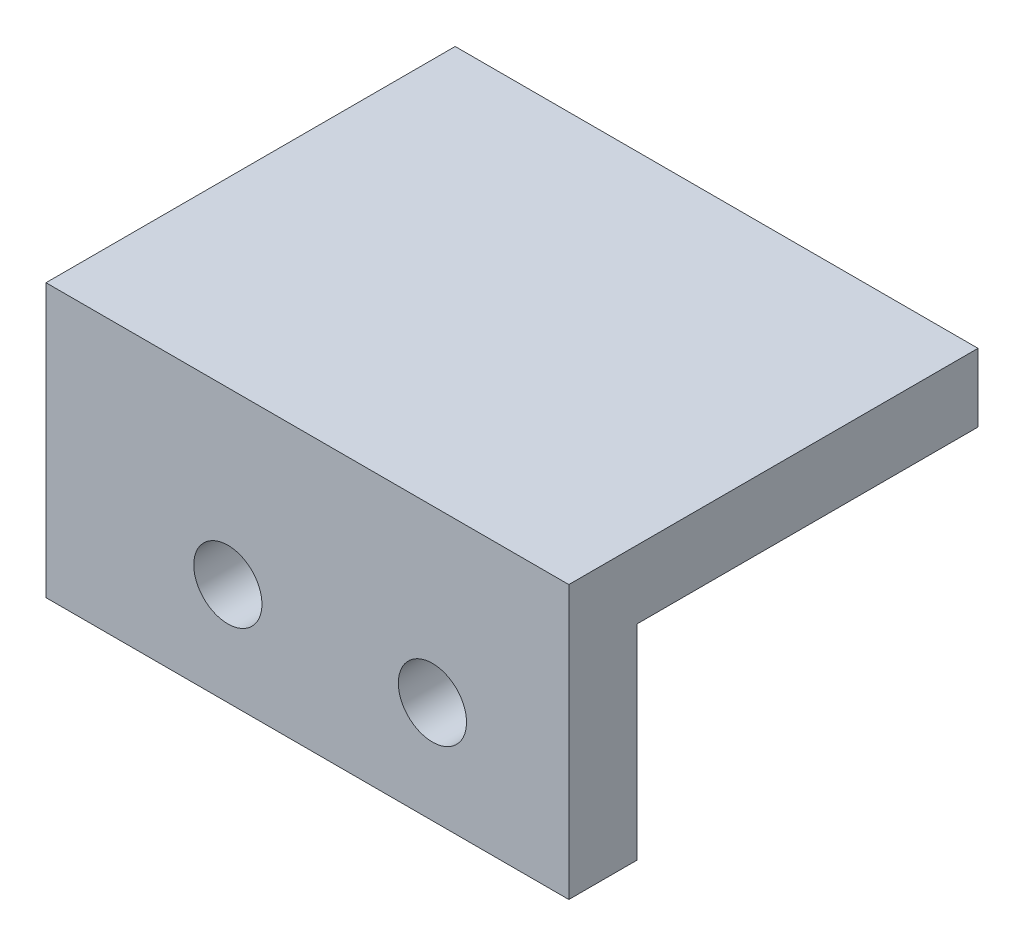
from build123d import *

# Parameters (mm, degrees)
CROQUIS1_W              = 23
CROQUIS1_H              = 12
SALIENTE_EXTRUIR1_DEPTH = 18
CROQUIS2_W              = 15
CROQUIS2_H              = 9
CORTAR_EXTRUIR1_DEPTH   = 20
CROQUIS3_W              = 1.1
CROQUIS3_H              = 9
CORTAR_EXTRUIR2_DEPTH   = 24
CROQUIS4_R              = 1.5
CORTAR_EXTRUIR3_DEPTH   = 4


with BuildPart() as part:
    # Croquis1 → Saliente-Extruir1 (new body)
    with BuildSketch(Plane.XY):
        Rectangle(CROQUIS1_W, CROQUIS1_H)
    extrude(amount=SALIENTE_EXTRUIR1_DEPTH)

    # Croquis2 → Cortar-Extruir1 (cut)
    with BuildSketch(Plane(origin=(11.5, 0, 0), x_dir=(0, 0, -1), z_dir=(1, 0, 0))):
        with Locations((-7.5, -1.5)):
            Rectangle(CROQUIS2_W, CROQUIS2_H)
    extrude(amount=-CORTAR_EXTRUIR1_DEPTH, mode=Mode.SUBTRACT)

    # Croquis3 → Cortar-Extruir2 (cut, through all)
    with BuildSketch(Plane.ZY.offset(11.5)):
        with Locations((14.45, -1.5)):
            Rectangle(CROQUIS3_W, CROQUIS3_H)
    extrude(amount=-CORTAR_EXTRUIR2_DEPTH, mode=Mode.SUBTRACT)

    # Croquis4 → Cortar-Extruir3 (cut, through all)
    with BuildSketch(Plane(origin=(0, 0, 15), x_dir=(-1, 0, 0), z_dir=(0, 0, -1))):
        with Locations((-5.5, -1.5)):
            Circle(CROQUIS4_R)
        with Locations((3.5, -1.5)):
            Circle(CROQUIS4_R)
    extrude(amount=-CORTAR_EXTRUIR3_DEPTH, mode=Mode.SUBTRACT)


solid = part.part
